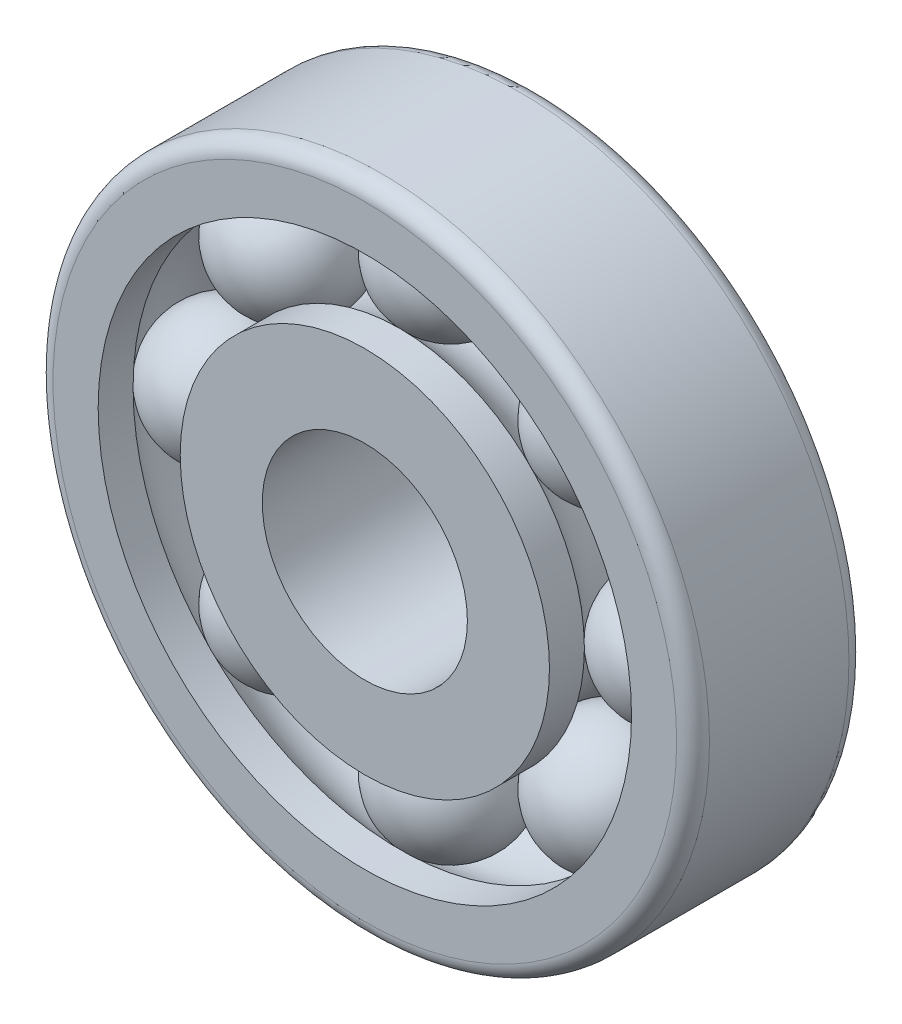
from build123d import *

# Parameters (mm, degrees)
SKETCH1_R             = 40
SKETCH1_R_2           = 32.5
BOSS_EXTRUDE1_DEPTH   = 21
SKETCH1_R_3           = 22.5
SKETCH1_R_4           = 12.5
BOSS_EXTRUDE1_2_DEPTH = 21
SKETCH2_R             = 8
CIRPATTERN1_COUNT     = 8
FILLET1_R             = 2


with BuildPart() as part:
    # Sketch1 → Boss-Extrude1 (new body)
    with BuildSketch(Plane.XY):
        Circle(SKETCH1_R)
        Circle(SKETCH1_R_2, mode=Mode.SUBTRACT)
    extrude(amount=BOSS_EXTRUDE1_DEPTH)


with BuildPart() as body_2:
    # Sketch1 → Boss-Extrude1 2 (new body)
    with BuildSketch(Plane.XY):
        Circle(SKETCH1_R_3)
        Circle(SKETCH1_R_4, mode=Mode.SUBTRACT)
    extrude(amount=BOSS_EXTRUDE1_2_DEPTH)


with BuildPart() as cut_revolve1_tool:
    # Sketch2 → Cut-Revolve1 (revolve)
    with BuildSketch(Plane(origin=(0, 0, 0), x_dir=(1, 0, 0), z_dir=(0, 1, 0))):
        with Locations((27.5, -10.5)):
            Circle(SKETCH2_R)
    revolve(axis=Axis((0, 0, 0), (0, 0, -1)))


with BuildPart() as part_1:
    add(part.part)

    # Cut-Revolve1: cut by cut_revolve1_tool
    add(cut_revolve1_tool.part, mode=Mode.SUBTRACT)

    # Fillet1
    fillet1_edges = [part_1.edges().sort_by_distance(p)[0] for p in [
        (-40, 0, 21),
        (-40, 0, 0),
    ]]
    fillet(fillet1_edges, radius=FILLET1_R)


with BuildPart() as body_2_1:
    add(body_2.part)

    # Cut-Revolve1: cut by cut_revolve1_tool
    add(cut_revolve1_tool.part, mode=Mode.SUBTRACT)


with BuildPart() as body_3:
    # Sketch3 → Revolve1 (revolve)
    with BuildSketch(Plane(origin=(0, 0, 0), x_dir=(1, 0, 0), z_dir=(0, 1, 0))):
        with BuildLine():
            Line((27.5, -2.5), (27.5, -18.5))
            ThreePointArc((27.5, -18.5), (35.5, -10.5), (27.5, -2.5))
        make_face()
    revolve(axis=Axis((27.5, 0, 2.5), (0, 0, 1)))


with BuildPart() as cirpattern1_1:
    # CirPattern1: pattern copy
    add(body_3.part.rotate(Axis((0, 0, 0), (0, 0, 1)), 1 * 360 / CIRPATTERN1_COUNT))


with BuildPart() as cirpattern1_2:
    # CirPattern1: pattern copy
    add(body_3.part.rotate(Axis((0, 0, 0), (0, 0, 1)), 2 * 360 / CIRPATTERN1_COUNT))


with BuildPart() as cirpattern1_3:
    # CirPattern1: pattern copy
    add(body_3.part.rotate(Axis((0, 0, 0), (0, 0, 1)), 3 * 360 / CIRPATTERN1_COUNT))


with BuildPart() as cirpattern1_4:
    # CirPattern1: pattern copy
    add(body_3.part.rotate(Axis((0, 0, 0), (0, 0, 1)), 4 * 360 / CIRPATTERN1_COUNT))


with BuildPart() as cirpattern1_5:
    # CirPattern1: pattern copy
    add(body_3.part.rotate(Axis((0, 0, 0), (0, 0, 1)), 5 * 360 / CIRPATTERN1_COUNT))


with BuildPart() as cirpattern1_6:
    # CirPattern1: pattern copy
    add(body_3.part.rotate(Axis((0, 0, 0), (0, 0, 1)), 6 * 360 / CIRPATTERN1_COUNT))


with BuildPart() as cirpattern1_7:
    # CirPattern1: pattern copy
    add(body_3.part.rotate(Axis((0, 0, 0), (0, 0, 1)), 7 * 360 / CIRPATTERN1_COUNT))


solid = Compound([part_1.part, body_2_1.part, body_3.part, cirpattern1_1.part, cirpattern1_2.part, cirpattern1_3.part, cirpattern1_4.part, cirpattern1_5.part, cirpattern1_6.part, cirpattern1_7.part])
